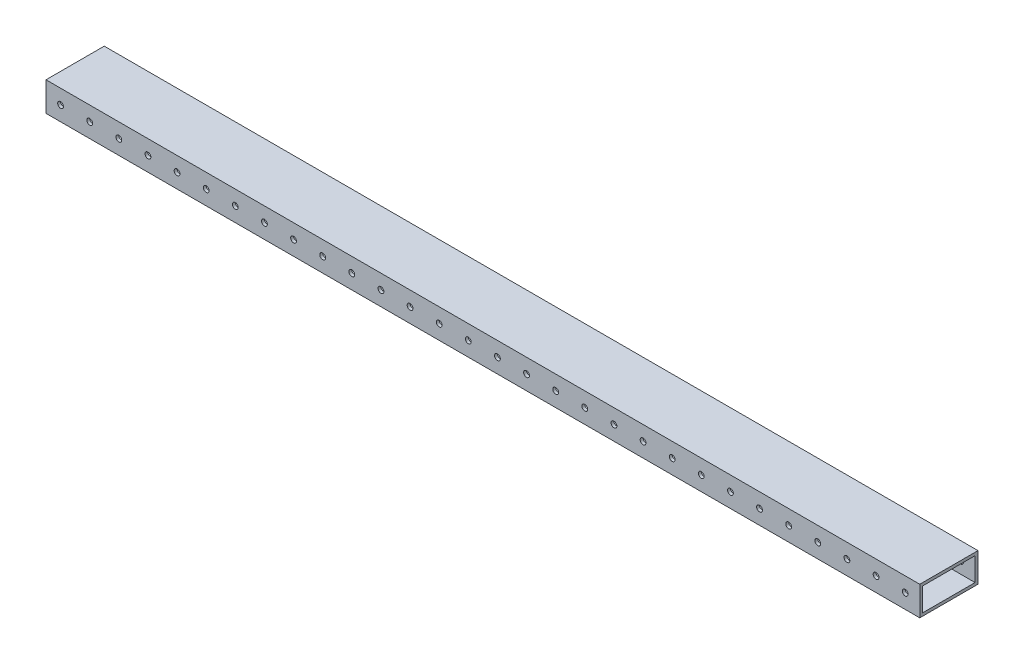
from build123d import *

# Parameters (mm, degrees)
SKETCH1_W           = 50.8
SKETCH1_H           = 25.4
SKETCH1_W_2         = 45.72
SKETCH1_H_2         = 20.32
BOSS_EXTRUDE1_DEPTH = 762
SKETCH2_R           = 2.54
CUT_EXTRUDE1_DEPTH  = 51.8
LPATTERN1_COUNT     = 30
LPATTERN1_PITCH     = 25.4


with BuildPart() as part:
    # Sketch1 → Boss-Extrude1 (new body)
    with BuildSketch(Plane(origin=(0, 0, 0), x_dir=(0, 0, -1), z_dir=(1, 0, 0))):
        with Locations((25.4, 12.7)):
            Rectangle(SKETCH1_W, SKETCH1_H)
        with Locations((25.4, 12.7)):
            Rectangle(SKETCH1_W_2, SKETCH1_H_2, mode=Mode.SUBTRACT)
    extrude(amount=BOSS_EXTRUDE1_DEPTH)

    # Sketch2 → Cut-Extrude1 (cut, through all)
    with BuildSketch(Plane.XY):
        with Locations((12.7, 12.7)):
            Circle(SKETCH2_R)
    cut_extrude1 = extrude(amount=-CUT_EXTRUDE1_DEPTH, mode=Mode.SUBTRACT)

    # LPattern1: Cut-Extrude1 ×30
    with Locations(*[(i * LPATTERN1_PITCH, 0, 0) for i in range(1, LPATTERN1_COUNT)]):
        add(cut_extrude1, mode=Mode.SUBTRACT)


solid = part.part
